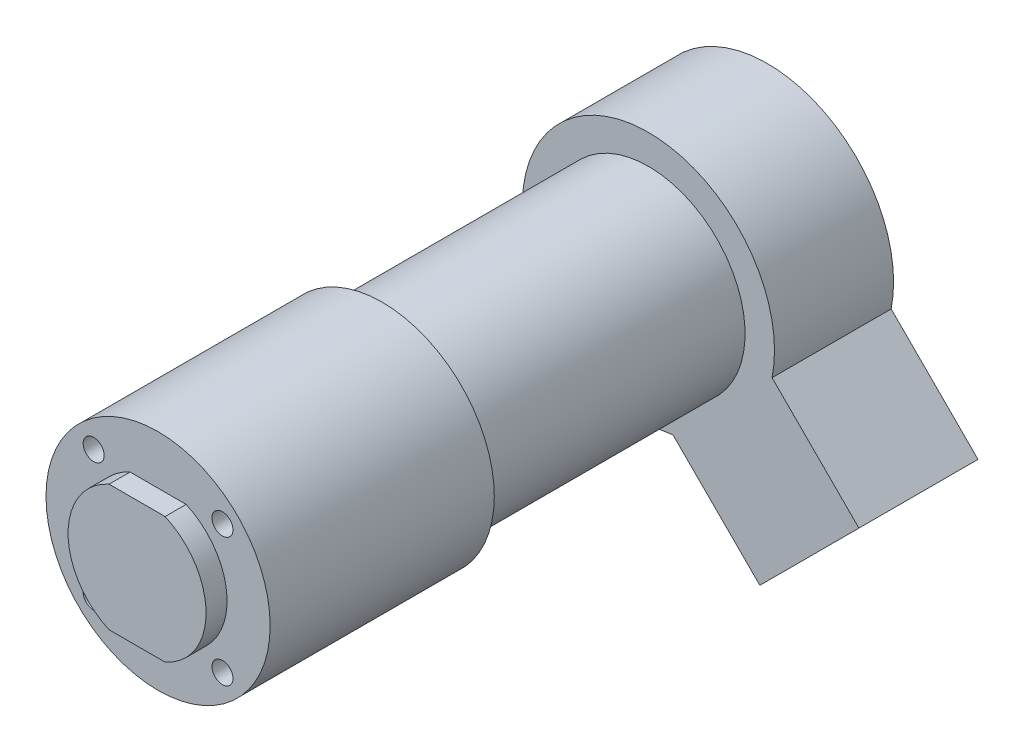
from build123d import *

# Parameters (mm, degrees)
BOSS_EXTRUDE1_DEPTH = 3
SKETCH2_R           = 16
BOSS_EXTRUDE2_DEPTH = 32
SKETCH3_R           = 13.8
BOSS_EXTRUDE3_DEPTH = 38
SKETCH4_R           = 18
SKETCH4_R_2         = 13.8
BOSS_EXTRUDE4_DEPTH = 17
SKETCH6_R           = 1.5
CUT_EXTRUDE1_DEPTH  = 10


with BuildPart() as part:
    # Sketch1 → Boss-Extrude1 (new body)
    with BuildSketch(Plane.XY):
        with BuildLine():
            Line((-4.002811512, 9), (4.002811512, 9))
            ThreePointArc((4.002811512, 9), (9.85, 0), (4.002811512, -9))
            Line((4.002811512, -9), (-4.002811512, -9))
            ThreePointArc((-4.002811512, -9), (-9.85, 0), (-4.002811512, 9))
        make_face()
    extrude(amount=BOSS_EXTRUDE1_DEPTH)

    # Sketch2 → Boss-Extrude2 (add)
    with BuildSketch(Plane(origin=(0, 0, 0), x_dir=(-1, 0, 0), z_dir=(0, 0, -1))):
        Circle(SKETCH2_R)
    extrude(amount=BOSS_EXTRUDE2_DEPTH)

    # Sketch3 → Boss-Extrude3 (add)
    with BuildSketch(Plane(origin=(0, 0, -32), x_dir=(-1, 0, 0), z_dir=(0, 0, -1))):
        Circle(SKETCH3_R)
    extrude(amount=BOSS_EXTRUDE3_DEPTH)

    # Sketch4 → Boss-Extrude4 (add)
    with BuildSketch(Plane(origin=(0, 0, -70), x_dir=(-1, 0, 0), z_dir=(0, 0, -1))):
        Circle(SKETCH4_R)
        Circle(SKETCH4_R_2, mode=Mode.SUBTRACT)
        Circle(SKETCH4_R_2)
        with BuildLine():
            Line((-17.654073056, -3.511937432), (-30.0520382, -15.909902577))
            Line((-30.0520382, -15.909902577), (-15.909902577, -30.0520382))
            Line((-15.909902577, -30.0520382), (-3.511937432, -17.654073056))
            ThreePointArc((-3.511937432, -17.654073056), (-12.727922061, -12.727922061), (-17.654073056, -3.511937432))
        make_face()
    extrude(amount=BOSS_EXTRUDE4_DEPTH)

    # Sketch6 → Cut-Extrude1 (cut)
    with BuildSketch(Plane.XY):
        with Locations((-9.192388155, 9.192388155)):
            Circle(SKETCH6_R)
        with Locations((9.192388155, 9.192388155)):
            Circle(SKETCH6_R)
        with Locations((9.192388155, -9.192388155)):
            Circle(SKETCH6_R)
        with Locations((-9.192388155, -9.192388155)):
            Circle(SKETCH6_R)
    extrude(amount=-CUT_EXTRUDE1_DEPTH, mode=Mode.SUBTRACT)


solid = part.part
